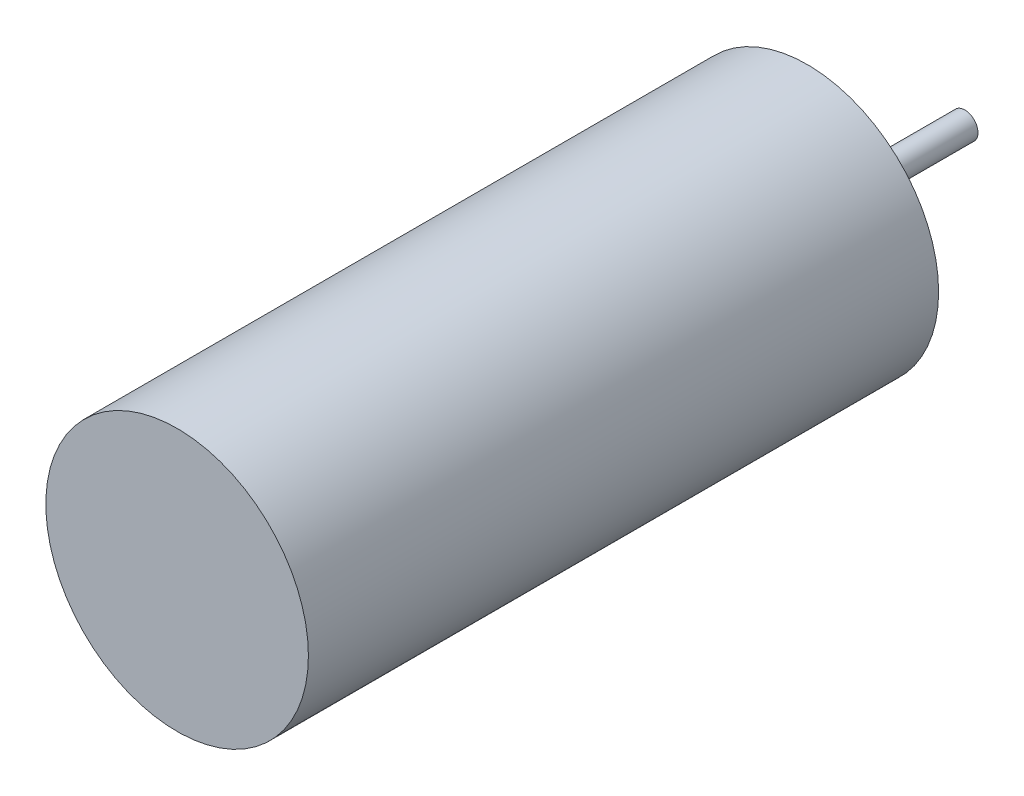
from build123d import *

# Parameters (mm, degrees)
SKETCH_1_R      = 2.5
EXTRUDE_1_DEPTH = 12
SKETCH_2_R      = 0.25
EXTRUDE_2_DEPTH = 3


with BuildPart() as part:
    # 草图1 → 凸台-拉伸1 (new body)
    with BuildSketch(Plane.XY):
        Circle(SKETCH_1_R)
    extrude(amount=EXTRUDE_1_DEPTH)

    # 草图2 → 凸台-拉伸2 (add)
    with BuildSketch(Plane(origin=(0, 0, 0), x_dir=(-1, 0, 0), z_dir=(0, 0, -1))):
        Circle(SKETCH_2_R)
    extrude(amount=EXTRUDE_2_DEPTH)


solid = part.part
